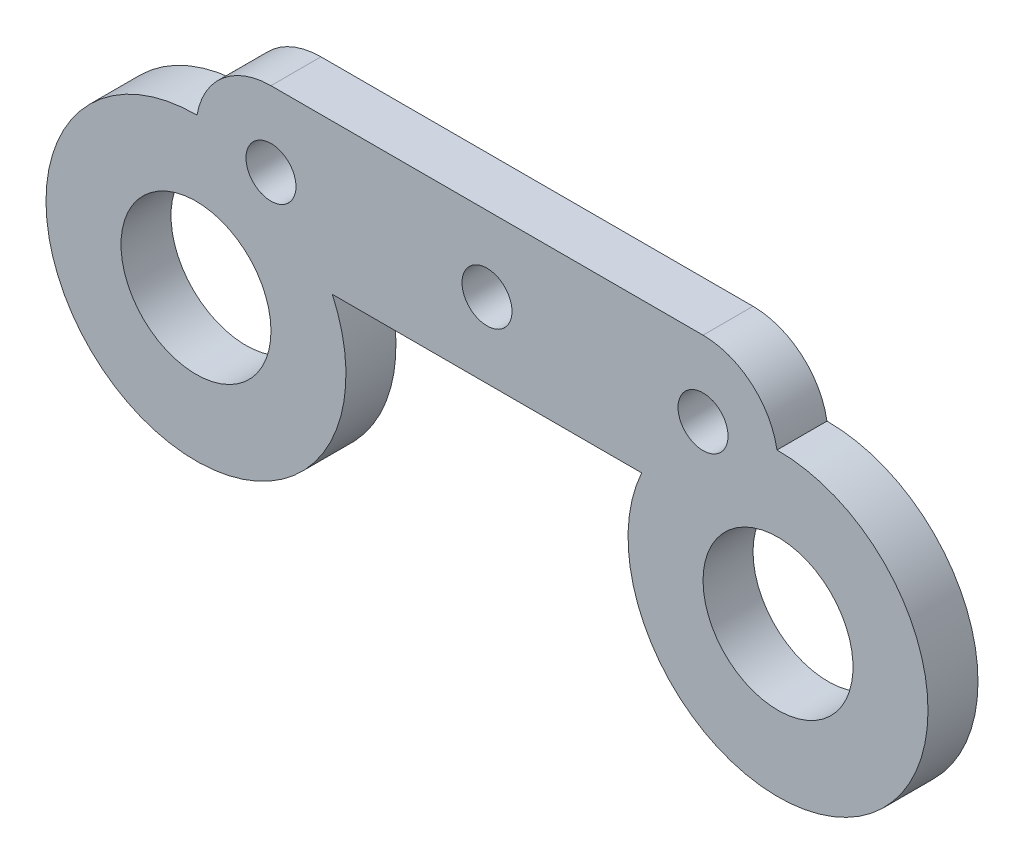
from build123d import *

# Parameters (mm, degrees)
SKETCH1_R           = 3
SKETCH1_R_2         = 1
BOSS_EXTRUDE1_DEPTH = 2
SKETCH2_R           = 0.5
CUT_EXTRUDE1_DEPTH  = 0.5


with BuildPart() as part:
    # Sketch1 → Boss-Extrude1 (new body)
    with BuildSketch(Plane.XY):
        with BuildLine():
            Line((-8.642138301, 3), (8.642138301, 3))
            ThreePointArc((8.642138301, 3), (10.578686732, 2.291239877), (11.600202961, 0.49985345))
            ThreePointArc((11.600202961, 0.49985345), (14.900135896, -10.538397729), (6.187782244, -3))
            Line((6.187782244, -3), (-6.187782244, -3))
            ThreePointArc((-6.187782244, -3), (-14.900135896, -10.538397729), (-11.600202961, 0.49985345))
            ThreePointArc((-11.600202961, 0.49985345), (-10.578686732, 2.291239877), (-8.642138301, 3))
        make_face()
        with Locations((-11.642138301, -5.5)):
            Circle(SKETCH1_R, mode=Mode.SUBTRACT)
        with Locations((11.642138301, -5.5)):
            Circle(SKETCH1_R, mode=Mode.SUBTRACT)
        with Locations((8.642138301, 0)):
            Circle(SKETCH1_R_2, mode=Mode.SUBTRACT)
        with Locations((-8.642138301, 0)):
            Circle(SKETCH1_R_2, mode=Mode.SUBTRACT)
        Circle(SKETCH1_R_2, mode=Mode.SUBTRACT)
    extrude(amount=BOSS_EXTRUDE1_DEPTH)

    # Sketch2 → Cut-Extrude1 (cut)
    with BuildSketch(Plane.XZ.offset(3)):
        with Locations((0, 1)):
            Circle(SKETCH2_R)
    extrude(amount=-CUT_EXTRUDE1_DEPTH, mode=Mode.SUBTRACT)


solid = part.part
